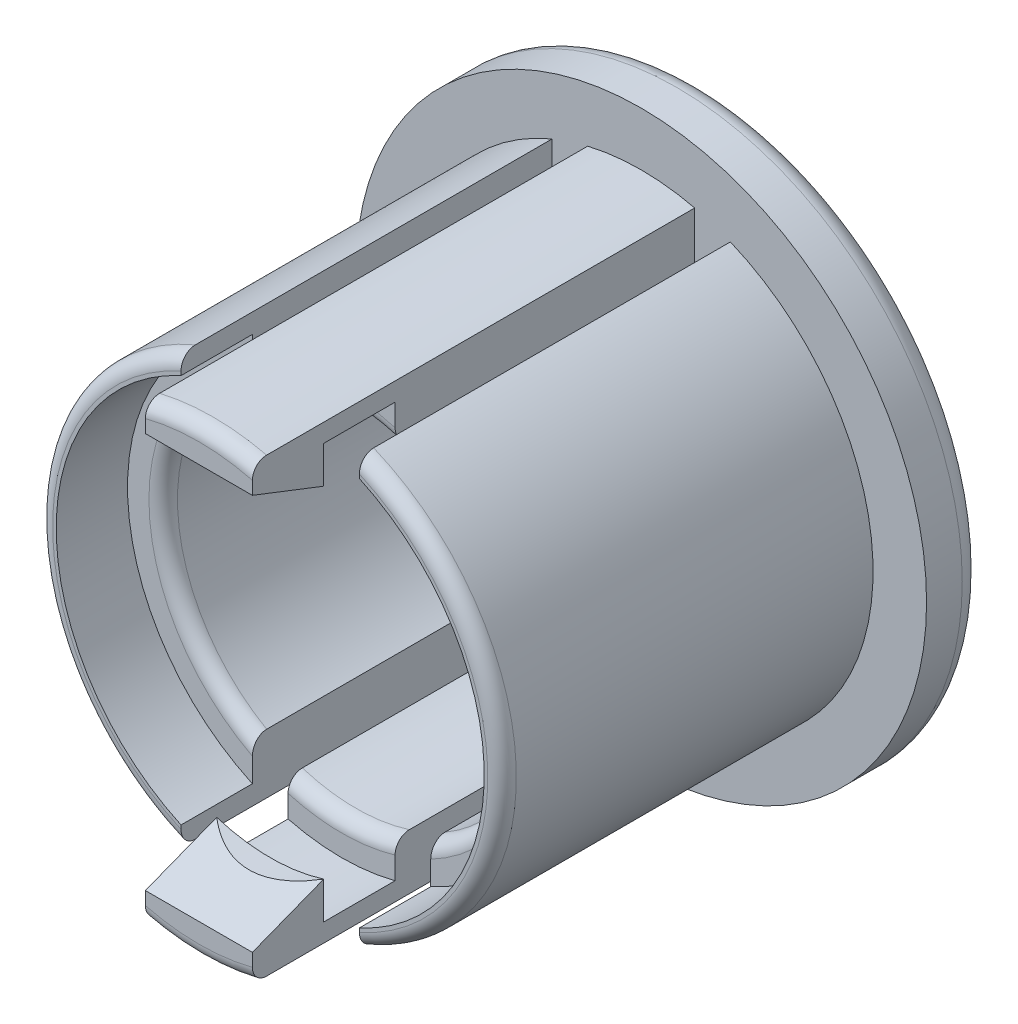
from build123d import *

# Parameters (mm, degrees)
SKETCH_1_R               = 4
EXTRUDE_1_DEPTH          = 0.8
SKETCH_2_R               = 3.25
EXTRUDE_2_DEPTH          = 6.2
SKETCH_3_R               = 2.5
CUT_EXTRUDE_1_DEPTH      = 1
CUT_EXTRUDE_1_DEPTH_BACK = 8
SKETCH_4_W               = 0.5
SKETCH_4_H               = 8
CUT_EXTRUDE_2_DEPTH      = 6.2
SKETCH_5_W               = 2
SKETCH_5_H               = 6
CUT_EXTRUDE_3_DEPTH      = 1
SKETCH_6_R               = 3
CUT_EXTRUDE_4_DEPTH      = 1
CUT_EXTRUDE_5_DEPTH      = 5.75
FILLET_1_R               = 0.3
FILLET_2_R               = 0.2


with BuildPart() as part:
    # Эскиз1 → Бобышка-Вытянуть1 (new body)
    with BuildSketch(Plane.XY):
        Circle(SKETCH_1_R)
    extrude(amount=EXTRUDE_1_DEPTH)

    # Эскиз2 → Бобышка-Вытянуть2 (add)
    with BuildSketch(Plane.XY.offset(0.8)):
        Circle(SKETCH_2_R)
    extrude(amount=EXTRUDE_2_DEPTH)

    # Эскиз3 → Вырез-Вытянуть1 (cut, two sides)
    with BuildSketch(Plane.XY.offset(7)) as cut_extrude_1_sk:
        Circle(SKETCH_3_R)
    extrude(amount=CUT_EXTRUDE_1_DEPTH, mode=Mode.SUBTRACT)
    extrude(cut_extrude_1_sk.sketch, amount=-CUT_EXTRUDE_1_DEPTH_BACK, mode=Mode.SUBTRACT)

    # Эскиз4 → Вырез-Вытянуть2 (cut)
    with BuildSketch(Plane.XY.offset(7)):
        with Locations((-1, 0)):
            Rectangle(SKETCH_4_W, SKETCH_4_H)
        with Locations((1, 0)):
            Rectangle(SKETCH_4_W, SKETCH_4_H)
    extrude(amount=-CUT_EXTRUDE_2_DEPTH, mode=Mode.SUBTRACT)

    # Эскиз5 → Вырез-Вытянуть3 (cut)
    with BuildSketch(Plane.XY.offset(7)):
        with Locations((-2.25, 0)):
            Rectangle(SKETCH_5_W, SKETCH_5_H)
        with Locations((2.25, 0)):
            Rectangle(SKETCH_5_W, SKETCH_5_H)
    extrude(amount=-CUT_EXTRUDE_3_DEPTH, mode=Mode.SUBTRACT)

    # Эскиз6 → Вырез-Вытянуть4 (cut)
    with BuildSketch(Plane.XY.offset(6)):
        Circle(SKETCH_6_R)
    extrude(amount=-CUT_EXTRUDE_4_DEPTH, mode=Mode.SUBTRACT)

    # Эскиз7 → Вырез-Вытянуть5 (cut, through all)
    with BuildSketch(Plane.ZY.offset(0.75)):
        Polygon((7, 2.773562832), (6, 2.384848004), (7, 2.384848004), align=None)
        Polygon((7, -2.773562832), (6, -2.384848004), (7, -2.384848004), align=None)
    extrude(amount=-CUT_EXTRUDE_5_DEPTH, mode=Mode.SUBTRACT)

    # Скругление1
    fillet_1_edges = [part.edges().sort_by_distance(p)[0] for p in [
        (-2.5, 0, 0),
        (-4, 0, 0),
    ]]
    fillet(fillet_1_edges, radius=FILLET_1_R)

    # Скругление2
    fillet_2_edges = [part.edges().sort_by_distance(p)[0] for p in [
        (-3.25, 0, 6),
        (3.25, 0, 6),
        (2.165063509, -1.25, 5),
        (0, -2.5, 5),
        (-2.5, 0, 5),
        (0, 2.5, 5),
        (0, -3.25, 7),
        (0, 3.25, 7),
    ]]
    fillet(fillet_2_edges, radius=FILLET_2_R)


solid = part.part
